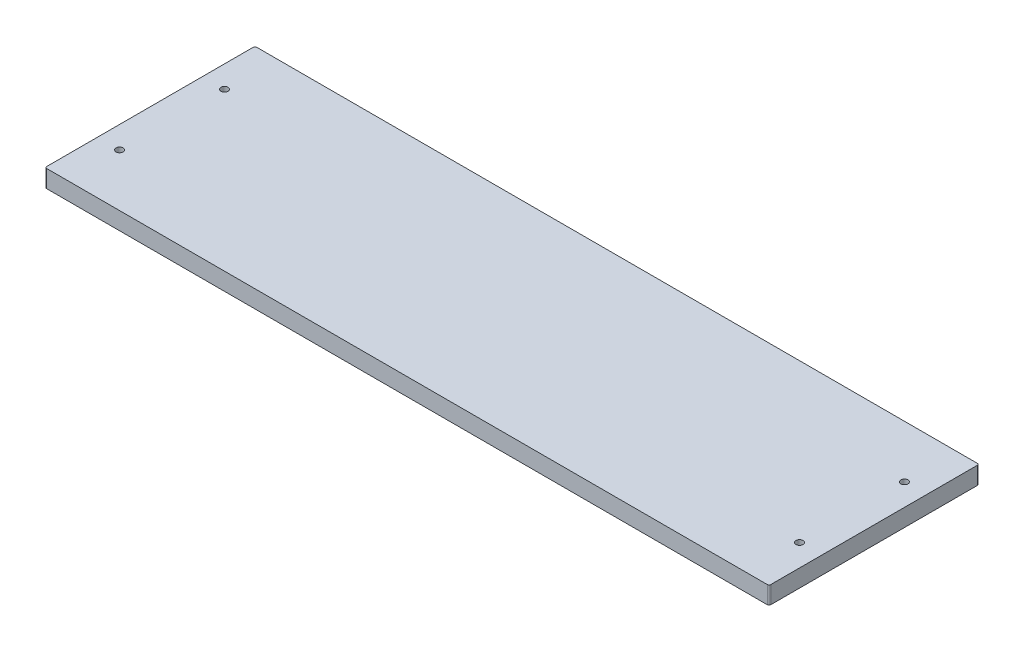
from build123d import *

# Parameters (mm, degrees)
SKETCH1_W              = 525.4625
SKETCH1_H              = 152.4
BOSS_EXTRUDE1_DEPTH    = 12.7
F_10_CLEARANCE_HOLE1_D = 5.1054
FILLET1_R              = 1.27


with BuildPart() as part:
    # Sketch1 → Boss-Extrude1 (new body)
    with BuildSketch(Plane(origin=(0, 0, 0), x_dir=(1, 0, 0), z_dir=(0, 1, 0))):
        Rectangle(SKETCH1_W, SKETCH1_H)
    extrude(amount=BOSS_EXTRUDE1_DEPTH)

    # #10 Clearance Hole1 (through all)
    with Locations(Plane(origin=(0, 12.7, 0), x_dir=(1, 0, 0), z_dir=(0, 1, 0))):
        with Locations((246.72925, -38.1), (-246.72925, 38.1), (-246.72925, -38.1), (246.72925, 38.1)):
            Hole(F_10_CLEARANCE_HOLE1_D / 2)

    # Fillet1
    fillet1_edges = [part.edges().sort_by_distance(p)[0] for p in [
        (262.73125, 6.35, 76.2),
        (-262.73125, 6.35, 76.2),
        (-262.73125, 6.35, -76.2),
        (262.73125, 6.35, -76.2),
    ]]
    fillet(fillet1_edges, radius=FILLET1_R)


solid = part.part
